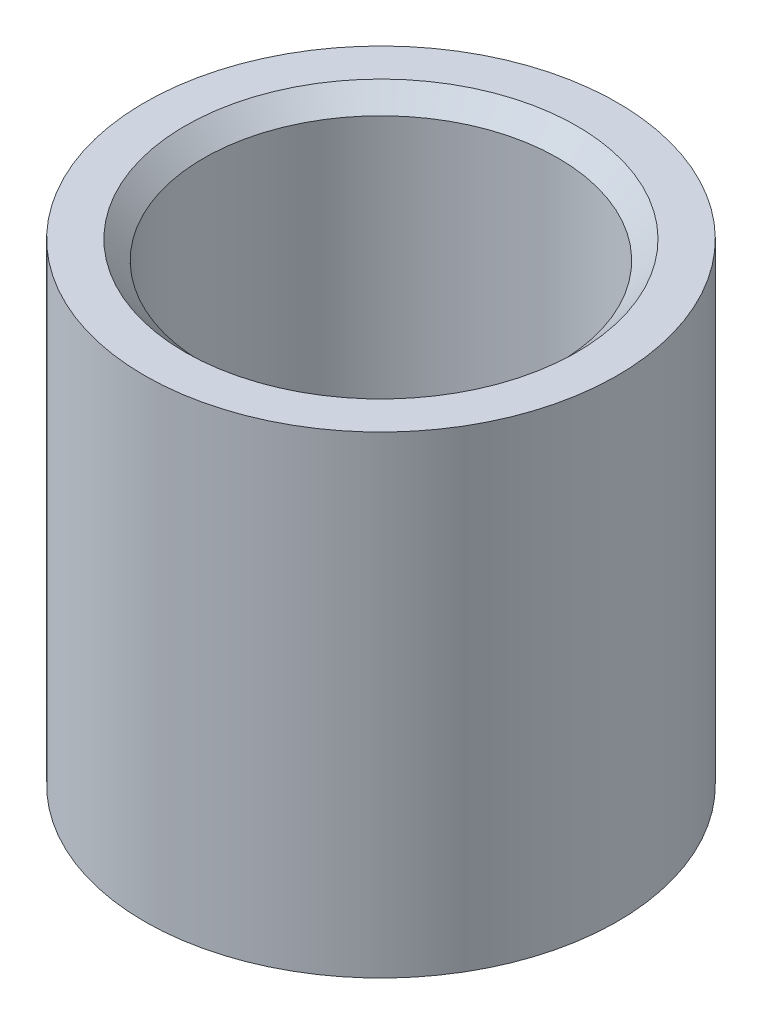
from build123d import *

# Parameters (mm, degrees)
SKETCH1_R           = 3.175
SKETCH1_R_2         = 2.38125
BOSS_EXTRUDE1_DEPTH = 6.35
CHAMFER1_SIZE       = 0.25


with BuildPart() as part:
    # Sketch1 → Boss-Extrude1 (new body)
    with BuildSketch(Plane(origin=(0, 0, 0), x_dir=(1, 0, 0), z_dir=(0, 1, 0))):
        Circle(SKETCH1_R)
        Circle(SKETCH1_R_2, mode=Mode.SUBTRACT)
    extrude(amount=BOSS_EXTRUDE1_DEPTH)

    # Chamfer1
    chamfer1_edges = [part.edges().sort_by_distance(p)[0] for p in [
        (-2.38125, 0, 0),
        (-2.38125, 6.35, 0),
    ]]
    chamfer(chamfer1_edges, length=CHAMFER1_SIZE)


solid = part.part
